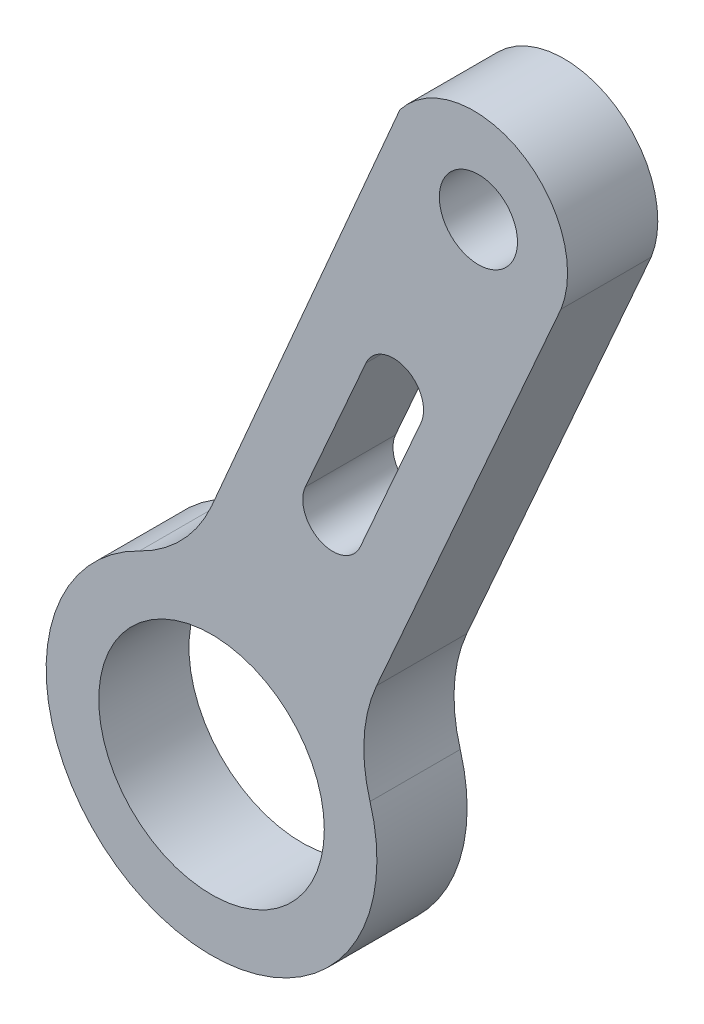
from build123d import *

# Parameters (mm, degrees)
MODEL_R             = 3.75005
MODEL_R_2           = 1.300000002
BOSS_EXTRUDE1_DEPTH = 3


with BuildPart() as part:
    # Model → Boss-Extrude1 (new body)
    with BuildSketch(Plane.XY):
        with BuildLine():
            Line((64.397506493, 42.115672183), (58.266368088, 28.207946902))
            ThreePointArc((58.266368088, 28.207946902), (57.851399273, 26.505567789), (58.049287259, 24.764552536))
            ThreePointArc((58.049287259, 24.764552536), (50.559319275, 18.162603648), (50.380520329, 28.145257626))
            ThreePointArc((50.380520329, 28.145257626), (51.799316654, 29.173568367), (52.776187572, 30.6282605))
            Line((52.776187572, 30.6282605), (59.040732097, 45.181361317))
            ThreePointArc((59.040732097, 45.181361317), (63.049082158, 45.972402409), (64.397506493, 42.115672183))
        make_face()
        with Locations((52.777915011, 23.195230557)):
            Circle(MODEL_R, mode=Mode.SUBTRACT)
        with Locations((61.652416233, 43.325828981)):
            Circle(MODEL_R_2, mode=Mode.SUBTRACT)
        with BuildLine():
            Line((59.743787463, 36.517324284), (57.726859465, 31.942173855))
            ThreePointArc((57.726859465, 31.942173855), (56.408443779, 31.430529369), (55.896799293, 32.748945054))
            Line((55.896799293, 32.748945054), (57.913727291, 37.324095484))
            ThreePointArc((57.913727291, 37.324095484), (59.232142977, 37.83573997), (59.743787463, 36.517324284))
        make_face(mode=Mode.SUBTRACT)
    extrude(amount=BOSS_EXTRUDE1_DEPTH)


solid = part.part
